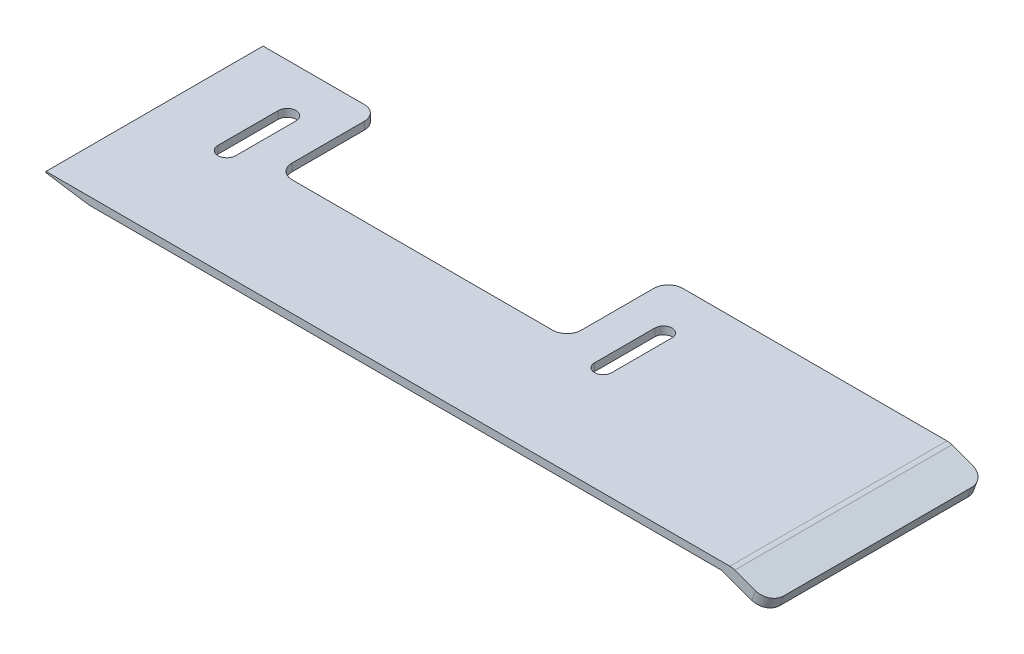
from build123d import *

# Parameters (mm, degrees)
BOSS_EXTRUDE1_DEPTH = 30
FILLET10_R          = 2
FILLET11_R          = 2
SKETCH4_W           = 40
SKETCH4_H           = 16.42245212
CUT_EXTRUDE1_DEPTH  = 30
FILLET12_R          = 2


with BuildPart() as part:
    # Sketch2 → Boss-Extrude1 (new body)
    with BuildSketch(Plane.XY):
        Polygon((-70.922010647, 6.21881141), (23.946585559, 6.21881141), (29.020925711, 4.371902636), (28.507895496, 2.962363705), (22.467605346, 5.160849526), (-64.922010647, 5.160849526), (-70.922010647, 6.060990271), align=None)
    extrude(amount=BOSS_EXTRUDE1_DEPTH)

    # Fillet10
    fillet10_edges = [part.edges().sort_by_distance(p)[0] for p in [
        (28.764410604, 3.667133171, 30),
        (28.764410604, 3.667133171, 0),
    ]]
    fillet(fillet10_edges, radius=FILLET10_R)

    # Fillet11
    fillet11_edges = [part.edges().sort_by_distance(p)[0] for p in [
        (23.946585559, 6.21881141, 15),
    ]]
    fillet(fillet11_edges, radius=FILLET11_R)

    # Sketch4 → Cut-Extrude1 (cut)
    with BuildSketch(Plane.XZ.offset(-5.160849526)):
        with Locations((-34.922010647, 5.78877394)):
            Rectangle(SKETCH4_W, SKETCH4_H)
        with BuildLine():
            Line((-59.68856271, 6.67422642), (-59.68856271, 15))
            ThreePointArc((-59.68856271, 15), (-60.922010647, 16.233447938), (-62.155458585, 15))
            Line((-62.155458585, 15), (-62.155458585, 6.67422642))
            ThreePointArc((-62.155458585, 6.67422642), (-60.922010647, 5.440778483), (-59.68856271, 6.67422642))
        make_face()
        with BuildLine():
            Line((-7.739956374, 6.67422642), (-7.739956374, 15))
            ThreePointArc((-7.739956374, 15), (-8.922010647, 16.182054274), (-10.104064921, 15))
            Line((-10.104064921, 15), (-10.104064921, 6.67422642))
            ThreePointArc((-10.104064921, 6.67422642), (-8.922010647, 5.492172147), (-7.739956374, 6.67422642))
        make_face()
    extrude(amount=-CUT_EXTRUDE1_DEPTH, mode=Mode.SUBTRACT)

    # Fillet12
    fillet12_edges = [part.edges().sort_by_distance(p)[0] for p in [
        (-54.922010647, 5.689830468, 0),
        (-14.922010647, 5.689830468, 0),
        (-54.922010647, 5.689830468, 14),
        (-14.922010647, 5.689830468, 14),
    ]]
    fillet(fillet12_edges, radius=FILLET12_R)


solid = part.part
